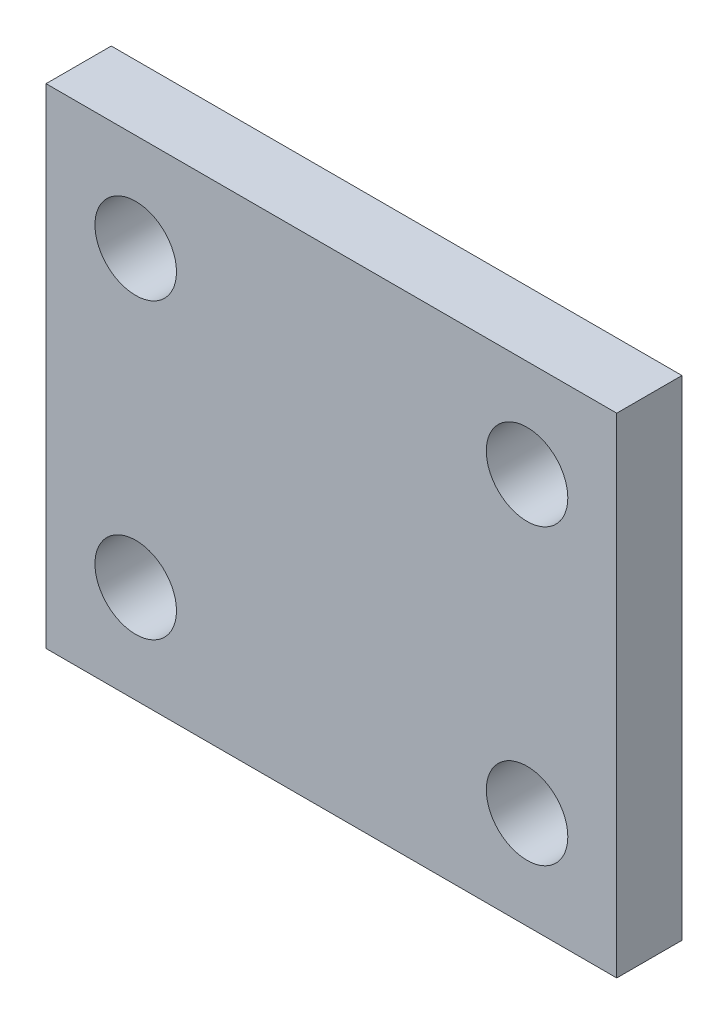
from build123d import *

# Parameters (mm, degrees)
SKETCH1_W           = 35
SKETCH1_H           = 30
SKETCH1_R           = 2.5
BOSS_EXTRUDE1_DEPTH = 4


with BuildPart() as part:
    # Sketch1 → Boss-Extrude1 (new body)
    with BuildSketch(Plane.XY):
        with Locations((17.5, 15)):
            Rectangle(SKETCH1_W, SKETCH1_H)
        with Locations((5.5, 24)):
            Circle(SKETCH1_R, mode=Mode.SUBTRACT)
        with Locations((29.5, 24)):
            Circle(SKETCH1_R, mode=Mode.SUBTRACT)
        with Locations((5.5, 6)):
            Circle(SKETCH1_R, mode=Mode.SUBTRACT)
        with Locations((29.5, 6)):
            Circle(SKETCH1_R, mode=Mode.SUBTRACT)
    extrude(amount=BOSS_EXTRUDE1_DEPTH)


solid = part.part
